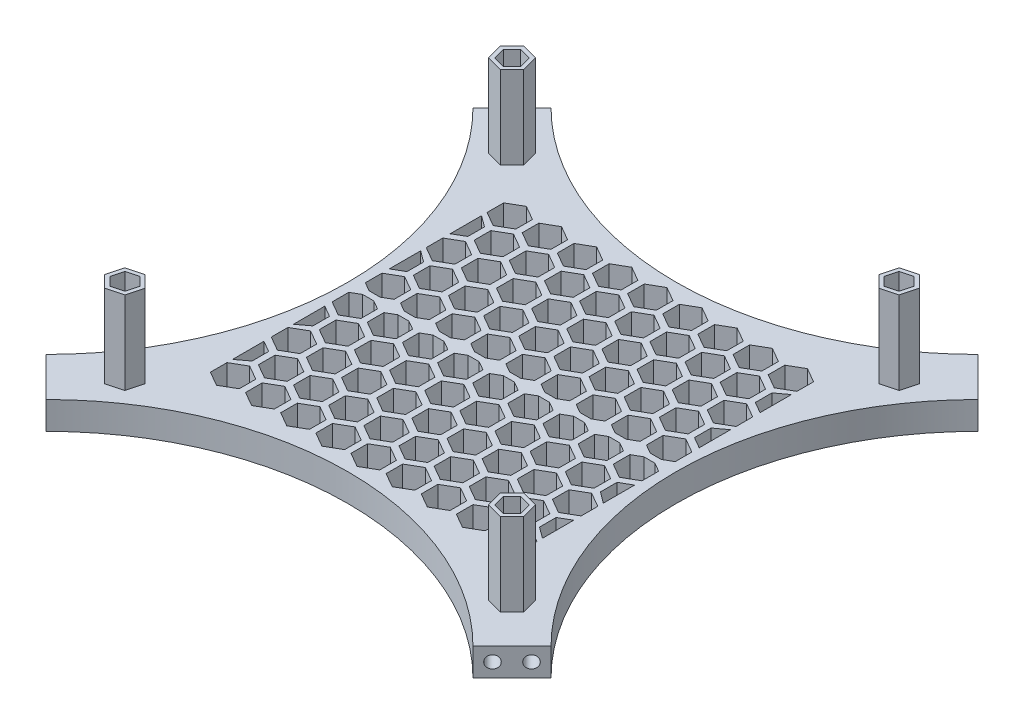
from build123d import *

# Parameters (mm, degrees)
BOSS_EXTRUDE1_DEPTH = 10
CUT_EXTRUDE1_DEPTH  = 11
BOSS_EXTRUDE2_DEPTH = 10
SKETCH11_R          = 2.25
CUT_EXTRUDE2_DEPTH  = 15
CIRPATTERN1_COUNT   = 4
BOSS_EXTRUDE3_DEPTH = 30
CIRPATTERN2_COUNT   = 4


with BuildPart() as part:
    # Sketch1 → Boss-Extrude1 (new body)
    with BuildSketch(Plane(origin=(0, 0, 0), x_dir=(1, 0, 0), z_dir=(0, 1, 0))):
        with BuildLine():
            Line((0, 0), (14.142135624, 14.142135624))
            ThreePointArc((14.142135624, 14.142135624), (91.5, -17.900540957), (168.857864376, 14.142135624))
            Line((168.857864376, 14.142135624), (183, 0))
            ThreePointArc((183, 0), (150.957323419, -77.357864376), (183, -154.715728753))
            Line((183, -154.715728753), (168.857864376, -168.857864376))
            ThreePointArc((168.857864376, -168.857864376), (91.5, -136.815187795), (14.142135624, -168.857864376))
            Line((14.142135624, -168.857864376), (0, -154.715728753))
            ThreePointArc((0, -154.715728753), (32.042676581, -77.357864376), (0, 0))
        make_face()
    extrude(amount=BOSS_EXTRUDE1_DEPTH)

    # Sketch9 → Cut-Extrude1 (cut, through all)
    with BuildSketch(Plane(origin=(0, 10, 0), x_dir=(1, 0, 0), z_dir=(0, 1, 0))):
        Polygon((40.566704624, -133.502525317), (45.778070189, -130.493742005), (45.778070189, -124.476175382), (40.566704624, -121.46739207), (35.355339059, -124.476175382), (35.355339059, -130.493742005), align=None)
        Polygon((41.722000981, -113.448793458), (46.933366546, -110.440010147), (52.144732111, -113.448793458), (52.144732111, -119.466360082), (46.933366546, -122.475143393), (41.722000981, -119.466360082), align=None)
        Polygon((147.644660941, -89.052256963), (147.644660941, -100.420379546), (143.588591733, -97.411596235), (143.588591733, -91.394029611), align=None)
        Polygon((54.455324825, -113.448793458), (59.66669039, -110.440010147), (64.878055955, -113.448793458), (64.878055955, -119.466360082), (59.66669039, -122.475143393), (54.455324825, -119.466360082), align=None)
        Polygon((58.511394033, -124.476175382), (53.300028468, -121.46739207), (48.088662903, -124.476175382), (48.088662903, -130.493742005), (53.300028468, -133.502525317), (58.511394033, -130.493742005), align=None)
        Polygon((67.188648669, -113.448793458), (72.400014234, -110.440010147), (77.611379799, -113.448793458), (77.611379799, -119.466360082), (72.400014234, -122.475143393), (67.188648669, -119.466360082), align=None)
        Polygon((71.244717877, -124.476175382), (66.033352312, -121.46739207), (60.821986747, -124.476175382), (60.821986747, -130.493742005), (66.033352312, -133.502525317), (71.244717877, -130.493742005), align=None)
        Polygon((79.921972513, -113.448793458), (85.133338078, -110.440010147), (90.344703643, -113.448793458), (90.344703643, -119.466360082), (85.133338078, -122.475143393), (79.921972513, -119.466360082), align=None)
        Polygon((83.978041721, -124.476175382), (78.766676156, -121.46739207), (73.555310591, -124.476175382), (73.555310591, -130.493742005), (78.766676156, -133.502525317), (83.978041721, -130.493742005), align=None)
        Polygon((92.655296357, -113.448793458), (97.866661922, -110.440010147), (103.078027487, -113.448793458), (103.078027487, -119.466360082), (97.866661922, -122.475143393), (92.655296357, -119.466360082), align=None)
        Polygon((96.711365565, -124.476175382), (91.5, -121.46739207), (86.288634435, -124.476175382), (86.288634435, -130.493742005), (91.5, -133.502525317), (96.711365565, -130.493742005), align=None)
        Polygon((105.388620201, -113.448793458), (110.599985766, -110.440010147), (115.811351331, -113.448793458), (115.811351331, -119.466360082), (110.599985766, -122.475143393), (105.388620201, -119.466360082), align=None)
        Polygon((109.444689409, -124.476175382), (104.233323844, -121.46739207), (99.021958279, -124.476175382), (99.021958279, -130.493742005), (104.233323844, -133.502525317), (109.444689409, -130.493742005), align=None)
        Polygon((118.121944045, -113.448793458), (123.33330961, -110.440010147), (128.544675175, -113.448793458), (128.544675175, -119.466360082), (123.33330961, -122.475143393), (118.121944045, -119.466360082), align=None)
        Polygon((122.178013253, -124.476175382), (116.966647688, -121.46739207), (111.755282123, -124.476175382), (111.755282123, -130.493742005), (116.966647688, -133.502525317), (122.178013253, -130.493742005), align=None)
        Polygon((130.855267889, -113.448793458), (136.066633454, -110.440010147), (141.277999019, -113.448793458), (141.277999019, -119.466360082), (136.066633454, -122.475143393), (130.855267889, -119.466360082), align=None)
        Polygon((134.911337097, -124.476175382), (129.699971532, -121.46739207), (124.488605967, -124.476175382), (124.488605967, -130.493742005), (129.699971532, -133.502525317), (134.911337097, -130.493742005), align=None)
        Polygon((147.644660941, -122.475143393), (143.588591733, -119.466360082), (143.588591733, -113.448793458), (147.644660941, -111.10702081), align=None)
        Polygon((39.411408267, -119.466360082), (39.411408267, -113.448793458), (35.355339059, -111.10702081), (35.355339059, -122.475143393), align=None)
        Polygon((147.644660941, -124.476175382), (142.433295376, -121.46739207), (137.221929811, -124.476175382), (137.221929811, -130.493742005), (142.433295376, -133.502525317), (147.644660941, -130.493742005), align=None)
        Polygon((54.455324825, -91.394029611), (59.66669039, -88.3852463), (64.878055955, -91.394029611), (64.878055955, -97.411596235), (59.66669039, -100.420379546), (54.455324825, -97.411596235), align=None)
        Polygon((58.511394033, -102.421411535), (53.300028468, -99.412628223), (48.088662903, -102.421411535), (48.088662903, -108.438978158), (53.300028468, -111.44776147), (58.511394033, -108.438978158), align=None)
        Polygon((67.188648669, -91.394029611), (72.400014234, -88.3852463), (77.611379799, -91.394029611), (77.611379799, -97.411596235), (72.400014234, -100.420379546), (67.188648669, -97.411596235), align=None)
        Polygon((71.244717877, -102.421411535), (66.033352312, -99.412628223), (60.821986747, -102.421411535), (60.821986747, -108.438978158), (66.033352312, -111.44776147), (71.244717877, -108.438978158), align=None)
        Polygon((79.921972513, -91.394029611), (85.133338078, -88.3852463), (90.344703643, -91.394029611), (90.344703643, -97.411596235), (85.133338078, -100.420379546), (79.921972513, -97.411596235), align=None)
        Polygon((83.978041721, -102.421411535), (78.766676156, -99.412628223), (73.555310591, -102.421411535), (73.555310591, -108.438978158), (78.766676156, -111.44776147), (83.978041721, -108.438978158), align=None)
        Polygon((92.655296357, -91.394029611), (97.866661922, -88.3852463), (103.078027487, -91.394029611), (103.078027487, -97.411596235), (97.866661922, -100.420379546), (92.655296357, -97.411596235), align=None)
        Polygon((96.711365565, -102.421411535), (91.5, -99.412628223), (86.288634435, -102.421411535), (86.288634435, -108.438978158), (91.5, -111.44776147), (96.711365565, -108.438978158), align=None)
        Polygon((105.388620201, -91.394029611), (110.599985766, -88.3852463), (115.811351331, -91.394029611), (115.811351331, -97.411596235), (110.599985766, -100.420379546), (105.388620201, -97.411596235), align=None)
        Polygon((109.444689409, -102.421411535), (104.233323844, -99.412628223), (99.021958279, -102.421411535), (99.021958279, -108.438978158), (104.233323844, -111.44776147), (109.444689409, -108.438978158), align=None)
        Polygon((118.121944045, -91.394029611), (123.33330961, -88.3852463), (128.544675175, -91.394029611), (128.544675175, -97.411596235), (123.33330961, -100.420379546), (118.121944045, -97.411596235), align=None)
        Polygon((122.178013253, -102.421411535), (116.966647688, -99.412628223), (111.755282123, -102.421411535), (111.755282123, -108.438978158), (116.966647688, -111.44776147), (122.178013253, -108.438978158), align=None)
        Polygon((130.855267889, -91.394029611), (136.066633454, -88.3852463), (141.277999019, -91.394029611), (141.277999019, -97.411596235), (136.066633454, -100.420379546), (130.855267889, -97.411596235), align=None)
        Polygon((134.911337097, -102.421411535), (129.699971532, -99.412628223), (124.488605967, -102.421411535), (124.488605967, -108.438978158), (129.699971532, -111.44776147), (134.911337097, -108.438978158), align=None)
        Polygon((147.644660941, -102.421411535), (142.433295376, -99.412628223), (137.221929811, -102.421411535), (137.221929811, -108.438978158), (142.433295376, -111.44776147), (147.644660941, -108.438978158), align=None)
        Polygon((39.411408267, -97.411596235), (39.411408267, -91.394029611), (35.355339059, -89.052256963), (35.355339059, -100.420379546), align=None)
        Polygon((58.511394033, -80.366647688), (53.300028468, -77.357864376), (48.088662903, -80.366647688), (48.088662903, -86.384214311), (53.300028468, -89.392997623), (58.511394033, -86.384214311), align=None)
        Polygon((71.244717877, -80.366647688), (66.033352312, -77.357864376), (60.821986747, -80.366647688), (60.821986747, -86.384214311), (66.033352312, -89.392997623), (71.244717877, -86.384214311), align=None)
        Polygon((83.978041721, -80.366647688), (78.766676156, -77.357864376), (73.555310591, -80.366647688), (73.555310591, -86.384214311), (78.766676156, -89.392997623), (83.978041721, -86.384214311), align=None)
        Polygon((96.711365565, -80.366647688), (91.5, -77.357864376), (86.288634435, -80.366647688), (86.288634435, -86.384214311), (91.5, -89.392997623), (96.711365565, -86.384214311), align=None)
        Polygon((109.444689409, -80.366647688), (104.233323844, -77.357864376), (99.021958279, -80.366647688), (99.021958279, -86.384214311), (104.233323844, -89.392997623), (109.444689409, -86.384214311), align=None)
        Polygon((122.178013253, -80.366647688), (116.966647688, -77.357864376), (111.755282123, -80.366647688), (111.755282123, -86.384214311), (116.966647688, -89.392997623), (122.178013253, -86.384214311), align=None)
        Polygon((134.911337097, -80.366647688), (129.699971532, -77.357864376), (124.488605967, -80.366647688), (124.488605967, -86.384214311), (129.699971532, -89.392997623), (134.911337097, -86.384214311), align=None)
        Polygon((147.644660941, -80.366647688), (142.433295376, -77.357864376), (137.221929811, -80.366647688), (137.221929811, -86.384214311), (142.433295376, -89.392997623), (147.644660941, -86.384214311), align=None)
        Polygon((41.722000981, -91.394029611), (46.933366546, -88.3852463), (52.144732111, -91.394029611), (52.144732111, -97.411596235), (46.933366546, -100.420379546), (41.722000981, -97.411596235), align=None)
        Polygon((45.778070189, -102.421411535), (40.566704624, -99.412628223), (35.355339059, -102.421411535), (35.355339059, -108.438978158), (40.566704624, -111.44776147), (45.778070189, -108.438978158), align=None)
        Polygon((45.778070189, -80.366647688), (40.566704624, -77.357864376), (35.355339059, -80.366647688), (35.355339059, -86.384214311), (40.566704624, -89.392997623), (45.778070189, -86.384214311), align=None)
    cut_extrude1 = extrude(amount=-CUT_EXTRUDE1_DEPTH, mode=Mode.SUBTRACT)

    # Mirror2: Cut-Extrude1 across plane
    add(cut_extrude1.mirror(Plane.XY.offset(77.36)), mode=Mode.SUBTRACT)

    # Sketch10 → Boss-Extrude2 (add)
    with BuildSketch(Plane(origin=(0, 10, 0), x_dir=(1, 0, 0), z_dir=(0, 1, 0))):
        with BuildLine():
            Line((150.963420565, -76.202864376), (32.036579435, -76.202864376))
            ThreePointArc((32.036579435, -76.202864376), (32.042676581, -77.357864376), (32.036579435, -78.512864376))
            Line((32.036579435, -78.512864376), (150.963420565, -78.512864376))
            ThreePointArc((150.963420565, -78.512864376), (150.957323419, -77.357864376), (150.963420565, -76.202864376))
        make_face()
    extrude(amount=-BOSS_EXTRUDE2_DEPTH)

    # Sketch11 → Cut-Extrude2 (cut)
    with BuildSketch(Plane(origin=(168.857864376, 0, 168.857864376), x_dir=(0.707106781, 0, -0.707106781), z_dir=(0.707106781, 0, 0.707106781))):
        with Locations((5, 5)):
            Circle(SKETCH11_R)
        with Locations((15, 5)):
            Circle(SKETCH11_R)
    cut_extrude2 = extrude(amount=-CUT_EXTRUDE2_DEPTH, mode=Mode.SUBTRACT)

    # CirPattern1: Cut-Extrude2 ×4 about axis
    cirpattern1_axis = Axis((91.5, 0, 77.357864376), (0, 1, 0))
    for i in range(1, CIRPATTERN1_COUNT):
        add(cut_extrude2.rotate(cirpattern1_axis, i * 360 / CIRPATTERN1_COUNT), mode=Mode.SUBTRACT)

    # Sketch13 → Boss-Extrude3 (add)
    with BuildSketch(Plane(origin=(0, 10, 0), x_dir=(1, 0, 0), z_dir=(0, 1, 0))):
        Polygon((19.805200612, -153.307725929), (25.617723625, -151.750265082), (27.175184473, -145.937742069), (22.920122307, -141.682679904), (17.107599294, -143.240140751), (15.550138447, -149.052663764), align=None)
        Polygon((24.474628412, -150.607169869), (25.613687372, -146.356143956), (22.50172042, -143.244177004), (18.250694507, -144.383235964), (17.111635547, -148.634261877), (20.223602499, -151.746228829), align=None, mode=Mode.SUBTRACT)
    boss_extrude3 = extrude(amount=BOSS_EXTRUDE3_DEPTH)

    # CirPattern2: Boss-Extrude3 ×4 about axis
    cirpattern2_axis = Axis((91.5, 0, 77.357864376), (0, 1, 0))
    for i in range(1, CIRPATTERN2_COUNT):
        add(boss_extrude3.rotate(cirpattern2_axis, i * 360 / CIRPATTERN2_COUNT))


solid = part.part
